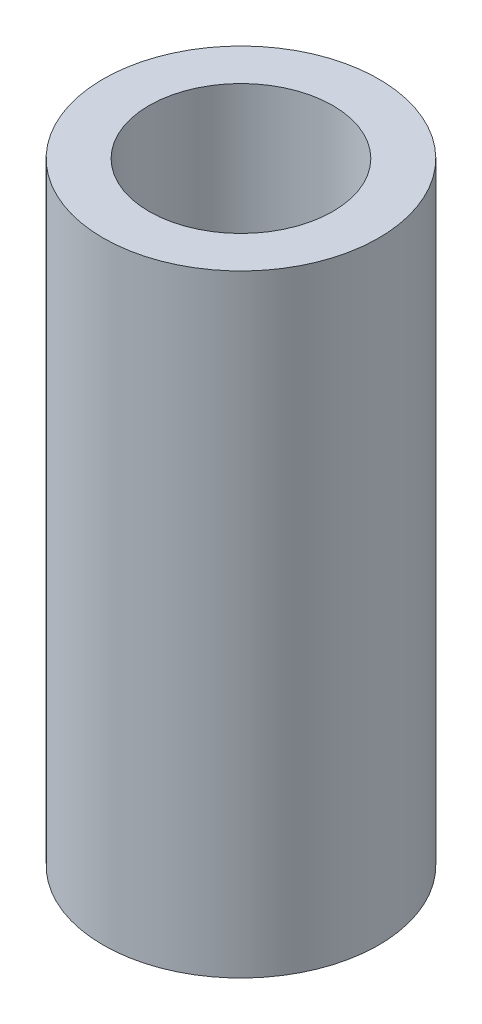
from build123d import *

# Parameters (mm, degrees)
SKETCH2_R           = 4.5
BOSS_EXTRUDE1_DEPTH = 20
SKETCH3_R           = 3
CUT_EXTRUDE1_DEPTH  = 10
SKETCH4_R           = 2.5
CUT_EXTRUDE2_DEPTH  = 10


with BuildPart() as part:
    # Sketch2 → Boss-Extrude1 (new body)
    with BuildSketch(Plane(origin=(0, 0, 0), x_dir=(1, 0, 0), z_dir=(0, 1, 0))):
        Circle(SKETCH2_R)
    extrude(amount=BOSS_EXTRUDE1_DEPTH)

    # Sketch3 → Cut-Extrude1 (cut)
    with BuildSketch(Plane(origin=(0, 20, 0), x_dir=(1, 0, 0), z_dir=(0, 1, 0))):
        Circle(SKETCH3_R)
    extrude(amount=-CUT_EXTRUDE1_DEPTH, mode=Mode.SUBTRACT)

    # Sketch4 → Cut-Extrude2 (cut)
    with BuildSketch(Plane.XZ):
        Circle(SKETCH4_R)
    extrude(amount=-CUT_EXTRUDE2_DEPTH, mode=Mode.SUBTRACT)


solid = part.part
